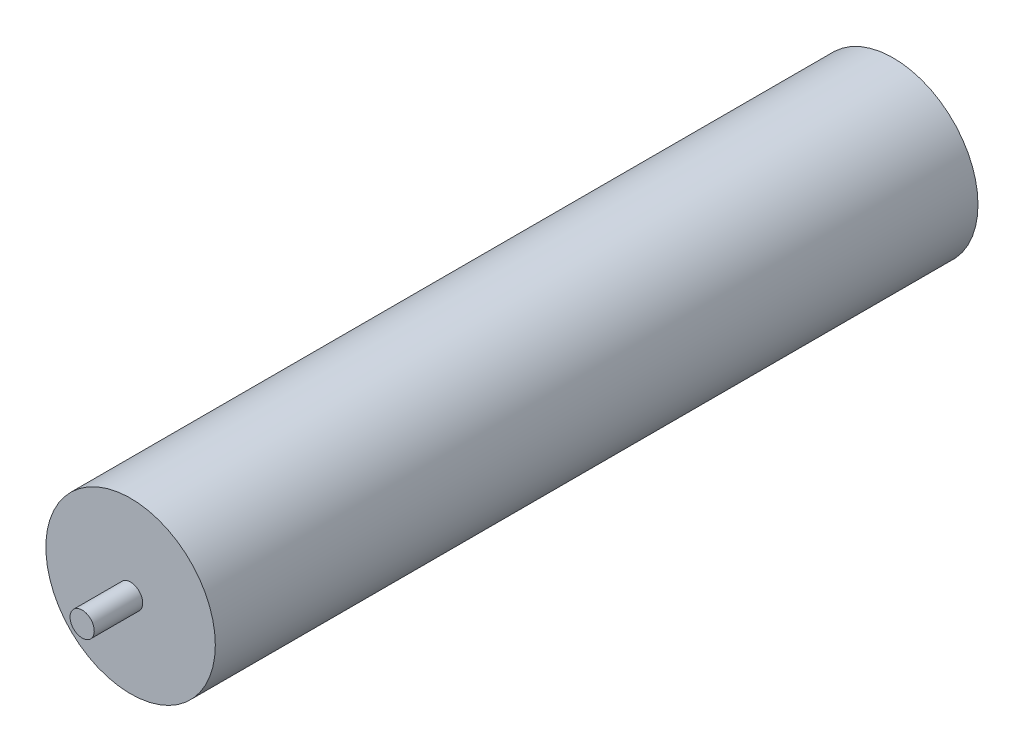
from build123d import *

# Parameters (mm, degrees)
SKETCH1_R           = 35
BOSS_EXTRUDE1_DEPTH = 315
SKETCH2_R           = 5
BOSS_EXTRUDE2_DEPTH = 20
SKETCH3_R           = 5
BOSS_EXTRUDE3_DEPTH = 20


with BuildPart() as part:
    # Sketch1 → Boss-Extrude1 (new body)
    with BuildSketch(Plane.XY):
        Circle(SKETCH1_R)
    extrude(amount=BOSS_EXTRUDE1_DEPTH)

    # Sketch2 → Boss-Extrude2 (add)
    with BuildSketch(Plane.XY.offset(315)):
        Circle(SKETCH2_R)
    extrude(amount=BOSS_EXTRUDE2_DEPTH)

    # Sketch3 → Boss-Extrude3 (add)
    with BuildSketch(Plane(origin=(0, 0, 0), x_dir=(-1, 0, 0), z_dir=(0, 0, -1))):
        Circle(SKETCH3_R)
    extrude(amount=BOSS_EXTRUDE3_DEPTH)


solid = part.part
